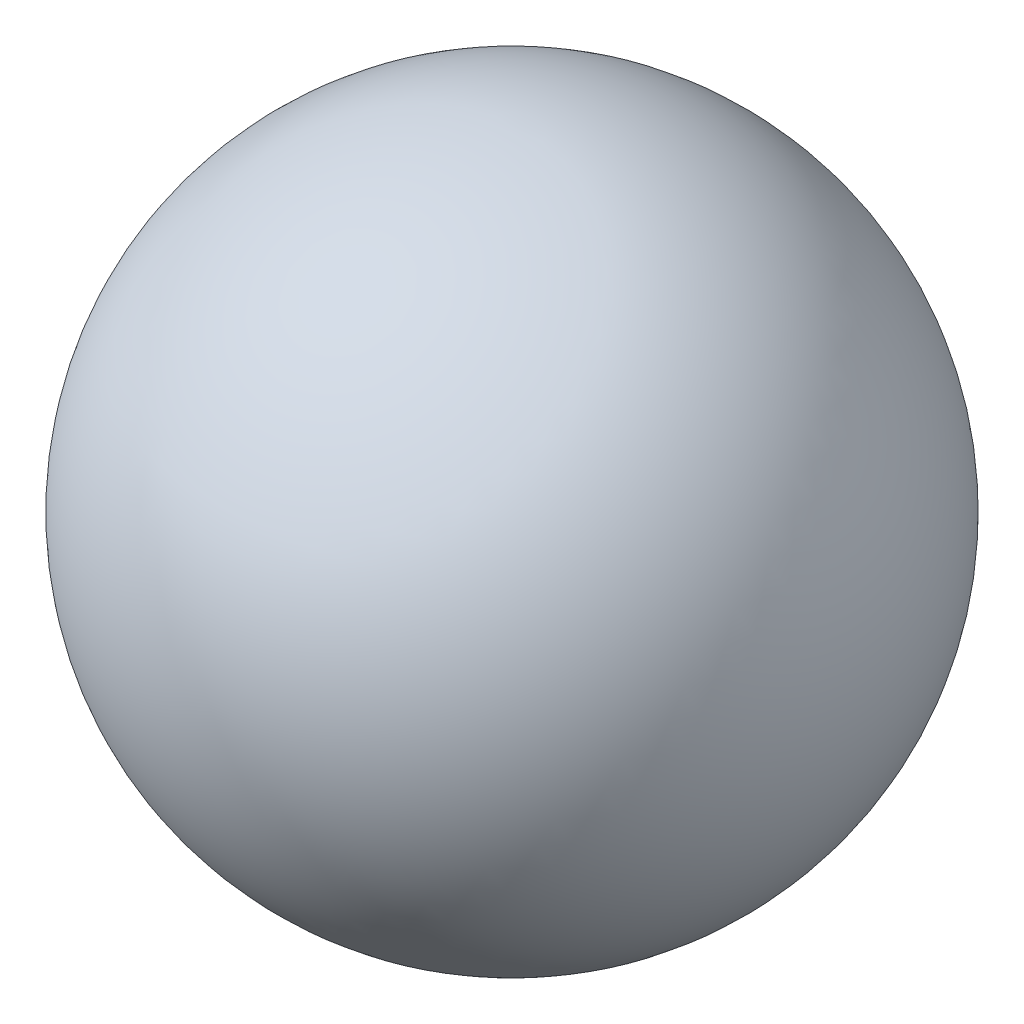
from build123d import *


with BuildPart() as part:
    # Sketch2 → Revolve1 (revolve)
    with BuildSketch(Plane.XY):
        with BuildLine():
            Line((0, 12.7), (0, 12.2174))
            ThreePointArc((0, 12.2174), (12.2174, 0), (0, -12.2174))
            Line((0, -12.2174), (0, -12.7))
            ThreePointArc((0, -12.7), (12.7, 0), (0, 12.7))
        make_face()
    revolve(axis=Axis((0, -158.486323131, 0), (0, 1, 0)))


solid = part.part
